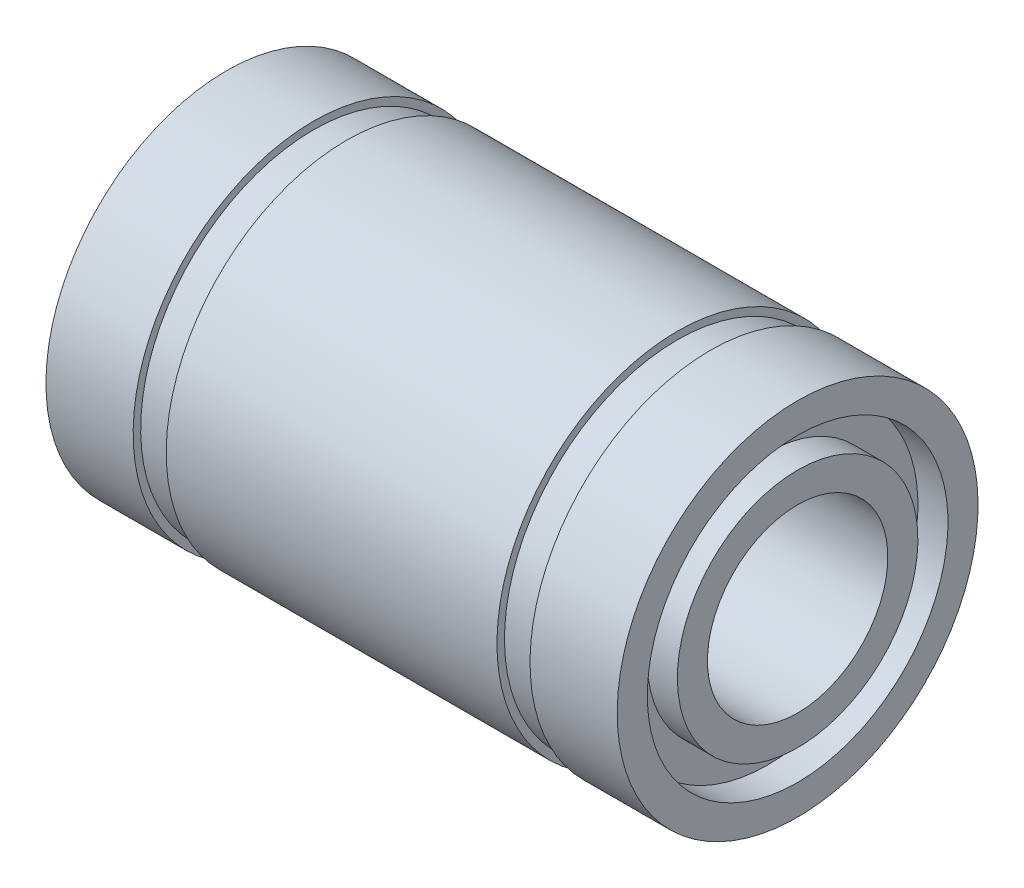
from build123d import *


with BuildPart() as part:
    # Esboço1 → Revolução1 (revolve)
    with BuildSketch(Plane.XY):
        Polygon((-9.5, 6), (-6.6, 6), (-6.6, 5.75), (-5.5, 5.75), (-5.5, 6), (5.5, 6), (5.5, 5.75), (6.6, 5.75), (6.6, 6), (9.5, 6), (9.5, 5), (8.5, 5), (8.5, 4), (9.5, 4), (9.5, 3), (-9.5, 3), (-9.5, 4), (-8.5, 4), (-8.5, 5), (-9.5, 5), align=None)
    revolve(axis=Axis((0, 0, 0), (-1, 0, 0)))


solid = part.part
